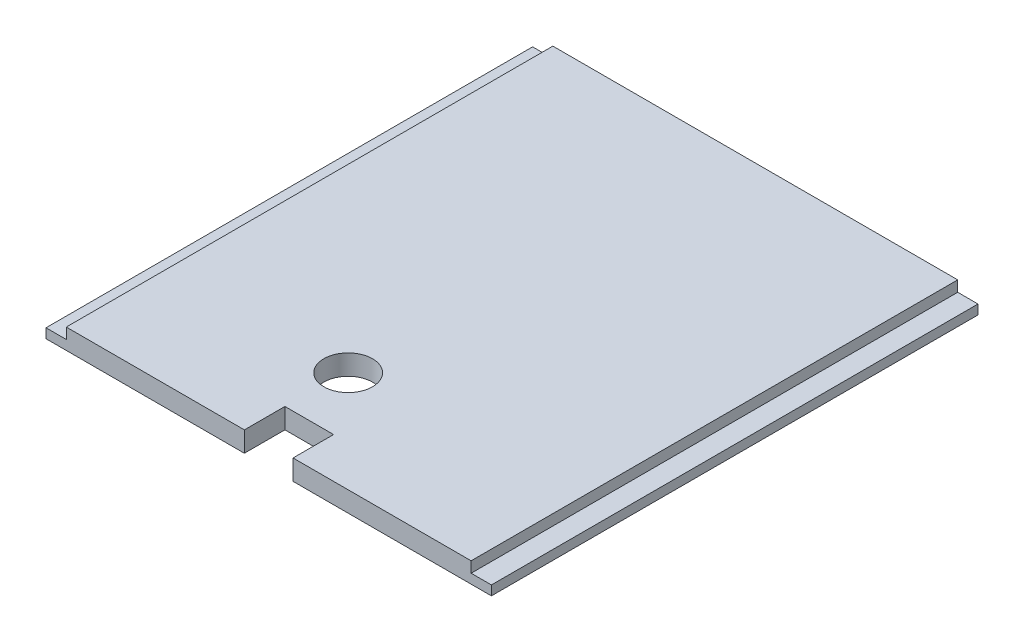
from build123d import *

# Parameters (mm, degrees)
SKETCH1_W           = 139.5
SKETCH1_H           = 152.4
BOSS_EXTRUDE1_DEPTH = 6.35
SKETCH2_W           = 6.35
SKETCH2_H           = 152.4
CUT_EXTRUDE1_DEPTH  = 3.375
SKETCH3_R           = 7.62
SKETCH3_W           = 15.24
SKETCH3_H           = 12.7
CUT_EXTRUDE2_DEPTH  = 7.35


with BuildPart() as part:
    # Sketch1 → Boss-Extrude1 (new body)
    with BuildSketch(Plane(origin=(0, 0, 0), x_dir=(1, 0, 0), z_dir=(0, 1, 0))):
        with Locations((69.75, 76.2)):
            Rectangle(SKETCH1_W, SKETCH1_H)
    extrude(amount=BOSS_EXTRUDE1_DEPTH)

    # Sketch2 → Cut-Extrude1 (cut)
    with BuildSketch(Plane(origin=(0, 6.35, 0), x_dir=(1, 0, 0), z_dir=(0, 1, 0))):
        with Locations((3.175, 76.2)):
            Rectangle(SKETCH2_W, SKETCH2_H)
        with Locations((136.325, 76.2)):
            Rectangle(SKETCH2_W, SKETCH2_H)
    extrude(amount=-CUT_EXTRUDE1_DEPTH, mode=Mode.SUBTRACT)

    # Sketch3 → Cut-Extrude2 (cut, through all)
    with BuildSketch(Plane(origin=(0, 6.35, 0), x_dir=(1, 0, 0), z_dir=(0, 1, 0))):
        with Locations((62.892, 31.75)):
            Circle(SKETCH3_R)
        with Locations((69.75, 6.35)):
            Rectangle(SKETCH3_W, SKETCH3_H)
    extrude(amount=-CUT_EXTRUDE2_DEPTH, mode=Mode.SUBTRACT)


solid = part.part
